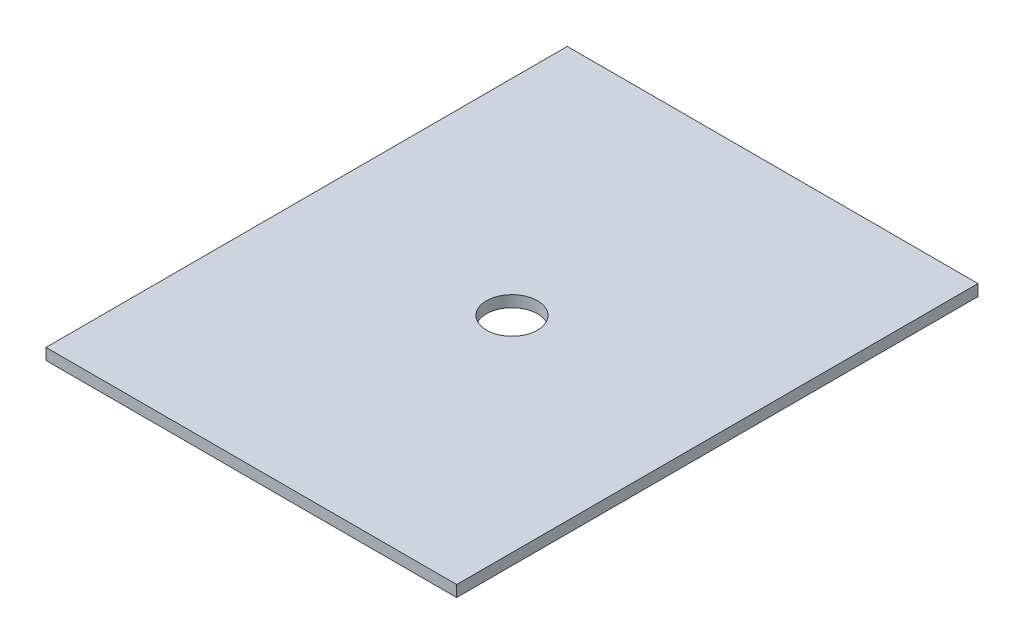
from build123d import *

# Parameters (mm, degrees)
SKETCH1_W           = 230.124
SKETCH1_H           = 292.1
BOSS_EXTRUDE1_DEPTH = 6.35
SKETCH2_R           = 14.2875
CUT_EXTRUDE1_DEPTH  = 6.35


with BuildPart() as part:
    # Sketch1 → Boss-Extrude1 (new body)
    with BuildSketch(Plane(origin=(0, 0, 0), x_dir=(1, 0, 0), z_dir=(0, 1, 0))):
        with Locations((115.062, 146.05)):
            Rectangle(SKETCH1_W, SKETCH1_H)
    extrude(amount=BOSS_EXTRUDE1_DEPTH)

    # Sketch2 → Cut-Extrude1 (cut)
    with BuildSketch(Plane(origin=(0, 6.35, 0), x_dir=(1, 0, 0), z_dir=(0, 1, 0))):
        with Locations((115.062, 146.05)):
            Circle(SKETCH2_R)
    extrude(amount=-CUT_EXTRUDE1_DEPTH, mode=Mode.SUBTRACT)


solid = part.part
